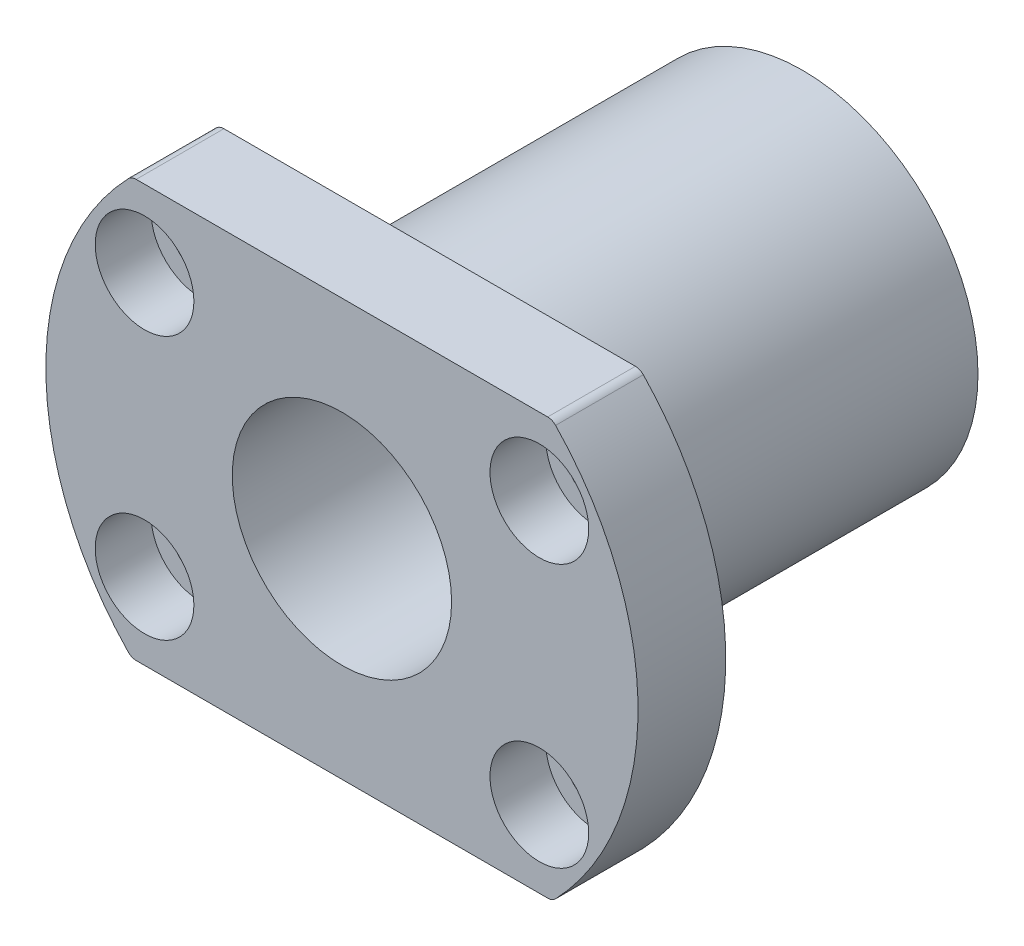
from build123d import *

# Parameters (mm, degrees)
SKETCH1_R                                           = 16
SKETCH1_R_2                                         = 10
BOSS_EXTRUDE1_DEPTH                                 = 34
SKETCH2_R                                           = 10
BOSS_EXTRUDE2_DEPTH                                 = 8
CBORE_FOR_M5_HEX_SOCKET_HEAD_CAP_SCREW1_D           = 5.5
CBORE_FOR_M5_HEX_SOCKET_HEAD_CAP_SCREW1_CBORE_D     = 9
CBORE_FOR_M5_HEX_SOCKET_HEAD_CAP_SCREW1_CBORE_DEPTH = 5.1
FILLET1_R                                           = 1


with BuildPart() as part:
    # Sketch1 → Boss-Extrude1 (new body)
    with BuildSketch(Plane.XY):
        Circle(SKETCH1_R)
        Circle(SKETCH1_R_2, mode=Mode.SUBTRACT)
    extrude(amount=BOSS_EXTRUDE1_DEPTH)

    # Sketch2 → Boss-Extrude2 (add)
    with BuildSketch(Plane.XY.offset(34)):
        with BuildLine():
            Line((-19.183326093, -19), (19.183326093, -19))
            ThreePointArc((19.183326093, -19), (27, 0), (19.183326093, 19))
            Line((19.183326093, 19), (-19.183326093, 19))
            ThreePointArc((-19.183326093, 19), (-27, 0), (-19.183326093, -19))
        make_face()
        Circle(SKETCH2_R, mode=Mode.SUBTRACT)
    extrude(amount=BOSS_EXTRUDE2_DEPTH)

    # CBORE for M5 Hex Socket Head Cap Screw1 (through all)
    with Locations(Plane(origin=(-18, -12, 42), x_dir=(1, 0, 0), z_dir=(0, 0, 1))):
        with Locations((0, 0), (0, 24), (36, 24), (36, 0)):
            CounterBoreHole(CBORE_FOR_M5_HEX_SOCKET_HEAD_CAP_SCREW1_D / 2, CBORE_FOR_M5_HEX_SOCKET_HEAD_CAP_SCREW1_CBORE_D / 2, CBORE_FOR_M5_HEX_SOCKET_HEAD_CAP_SCREW1_CBORE_DEPTH)

    # Fillet1
    fillet1_edges = [part.edges().sort_by_distance(p)[0] for p in [
        (-19.183326093, 19, 38),
        (-19.183326093, -19, 38),
        (19.183326093, -19, 38),
        (19.183326093, 19, 38),
    ]]
    fillet(fillet1_edges, radius=FILLET1_R)


solid = part.part
